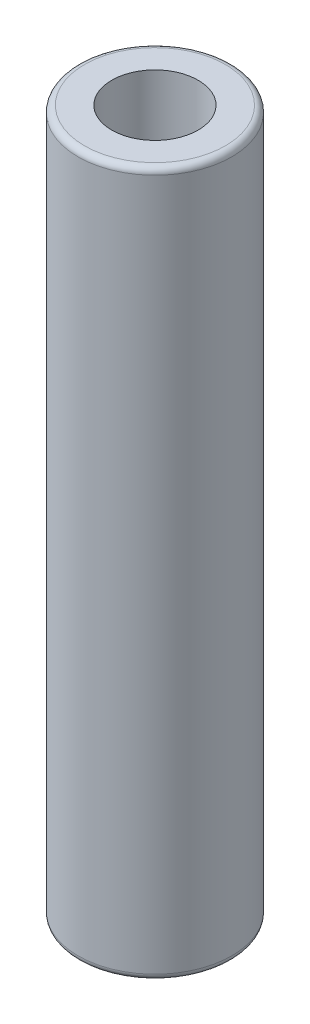
from build123d import *

# Parameters (mm, degrees)
F_1_2_13_TAPPED_HOLE1_D     = 10.71626
F_1_2_13_TAPPED_HOLE1_DEPTH = 19.05
F_1_2_13_TAPPED_HOLE1_TIP   = 3.219489309


with BuildPart() as part:
    # Sketch1 → Revolve1 (revolve)
    with BuildSketch(Plane.XY):
        with BuildLine():
            Line((0, 0), (0, 43.6753))
            Line((0, 43.6753), (8.73125, 43.6753))
            ThreePointArc((8.73125, 43.6753), (9.292516008, 43.442816008), (9.525, 42.88155))
            Line((9.525, 42.88155), (9.525, 0))
            Line((9.525, 0), (0, 0))
        make_face()
    revolve(axis=Axis((0, 543.005217441, 0), (0, -1, 0)))

    # 1/2-13 Tapped Hole1
    with Locations(Plane(origin=(0, 43.6753, 0), x_dir=(1, 0, 0), z_dir=(0, 1, 0))):
        with Locations((0, 0)):
            Hole(F_1_2_13_TAPPED_HOLE1_D / 2, depth=F_1_2_13_TAPPED_HOLE1_DEPTH)
            with Locations((0, 0, -(F_1_2_13_TAPPED_HOLE1_DEPTH + F_1_2_13_TAPPED_HOLE1_TIP / 2))):  # 118° drill point
                Cone(0, F_1_2_13_TAPPED_HOLE1_D / 2, F_1_2_13_TAPPED_HOLE1_TIP, mode=Mode.SUBTRACT)

    # Mirror1: part across plane


with BuildPart() as part_1:
    add(part.part)
    add(part.part.mirror(Plane.ZX))


solid = part_1.part
